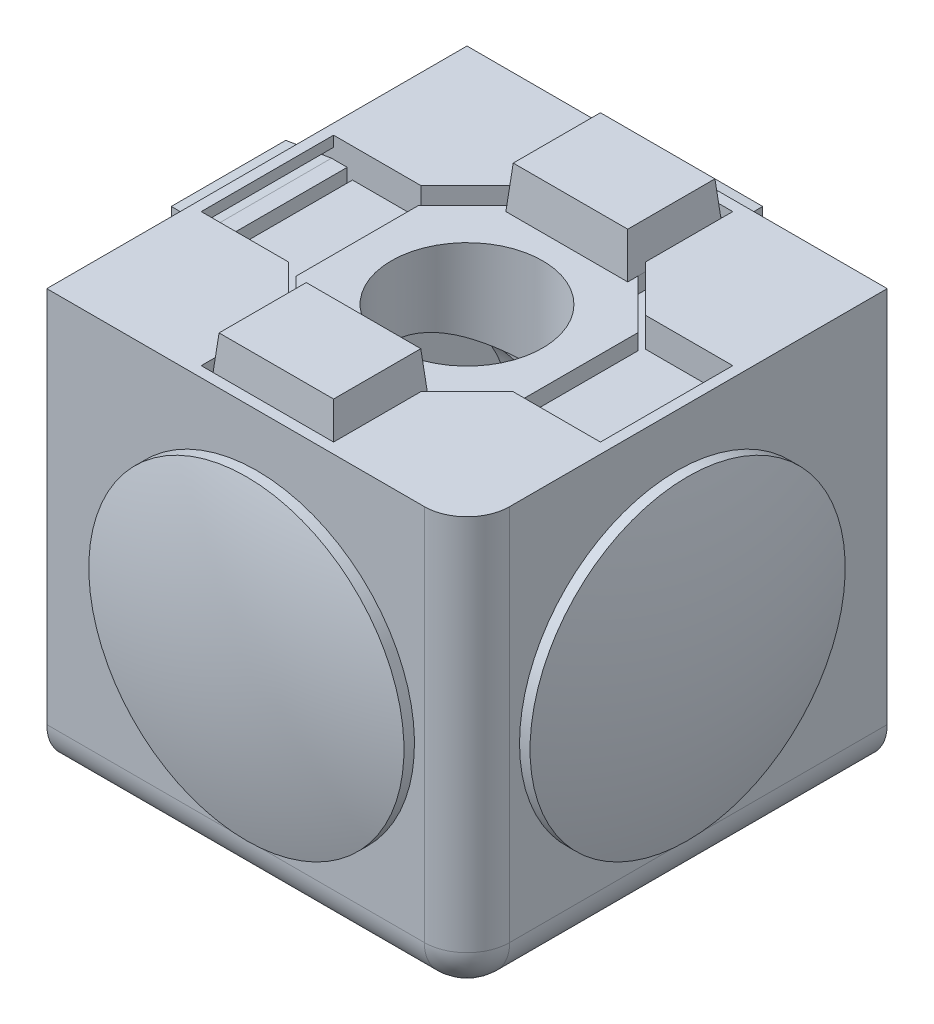
from build123d import *

# Parameters (mm, degrees)
SKETCH1_W                   = 20
SKETCH1_H                   = 20
EXTRUDE1_DEPTH              = 10
SKETCH2_R                   = 6
CUT_EXTRUDE1_DEPTH          = 25.494897428
EXTRUDE2_START              = -6
SKETCH4_R                   = 6
SKETCH4_R_2                 = 3.6
EXTRUDE2_DEPTH              = 6
CUT_EXTRUDE7_DEPTH          = 1.4
SKETCH15_R                  = 3.6
EXTRUDE4_DEPTH              = 0.75
SKETCH16_W                  = 5.8
SKETCH16_H                  = 4.5
EXTRUDE5_DEPTH              = 2
EXTRUDE5_DRAFT              = 5
EXTRUDE5_PROFILE_2_DEPTH    = 2
EXTRUDE5_PROFILE_2_DRAFT    = 5
CIRPATTERN1_COUNT           = 2
CIRPATTERN1_ANGLE           = 90
CIRPATTERN1_COPY_1_SKETCH_W = 5.8
CIRPATTERN1_COPY_1_SKETCH_H = 4.5
CIRPATTERN1_COPY_1_DEPTH    = 2
CIRPATTERN1_COPY_1_DRAFT    = 5
CIRPATTERN1_COPY_2_SKETCH_W = 5.8
CIRPATTERN1_COPY_2_SKETCH_H = 4.5
CIRPATTERN1_COPY_2_DEPTH    = 2
CIRPATTERN1_COPY_2_DRAFT    = 5
CIRPATTERN1_COPY_3_SKETCH_W = 5.8
CIRPATTERN1_COPY_3_SKETCH_H = 4.5
CIRPATTERN1_COPY_3_DEPTH    = 2
CIRPATTERN1_COPY_3_DRAFT    = 5
CIRPATTERN2_COUNT           = 2
CIRPATTERN2_ANGLE           = 90
CIRPATTERN2_COPY_1_SKETCH_W = 5.8
CIRPATTERN2_COPY_1_SKETCH_H = 4.5
CIRPATTERN2_COPY_1_DEPTH    = 2
CIRPATTERN2_COPY_1_DRAFT    = 5
CIRPATTERN2_COPY_2_SKETCH_W = 5.8
CIRPATTERN2_COPY_2_SKETCH_H = 4.5
CIRPATTERN2_COPY_2_DEPTH    = 2
CIRPATTERN2_COPY_2_DRAFT    = 5
CIRPATTERN2_COPY_3_SKETCH_W = 5.8
CIRPATTERN2_COPY_3_SKETCH_H = 4.5
CIRPATTERN2_COPY_3_DEPTH    = 2
CIRPATTERN2_COPY_3_DRAFT    = 5
FILLET2_R                   = 2.032


with BuildPart() as part:
    # Sketch1 → Extrude1 (new, symmetric)
    with BuildSketch(Plane.XY):
        Rectangle(SKETCH1_W, SKETCH1_H)
    extrude(amount=EXTRUDE1_DEPTH, both=True)

    # Sketch2 → Cut-Extrude1 (cut, through all)
    with BuildSketch(Plane.XY.offset(10)):
        Circle(SKETCH2_R)
    cut_extrude1 = extrude(amount=-CUT_EXTRUDE1_DEPTH, mode=Mode.SUBTRACT)

    # Cut-Extrude2 cone 1 section (through the dimple's axis) → Cut-Extrude2 (revolve, cut)
    with BuildSketch(Plane(origin=(0, 0, 10), x_dir=(0, -1, 0), z_dir=(1, 0, 0))):
        Polygon((0, 0), (7.05, 0), (0, 7.05), align=None)
    cut_extrude2 = revolve(axis=Axis((0, 0, 10), (0, 0, -1)), mode=Mode.SUBTRACT)

    # Sketch4 → Extrude2 (add)
    with BuildSketch(Plane(origin=(0, 0, -10), x_dir=(-1, 0, 0), z_dir=(0, 0, -1)).offset(EXTRUDE2_START)):
        with Locations(Location((0, 0, 0), (0, 0, 180))):
            Circle(SKETCH4_R)
        Circle(SKETCH4_R_2, mode=Mode.SUBTRACT)
    extrude2 = extrude(amount=EXTRUDE2_DEPTH)

    # Sketch14 → Cut-Extrude7 (cut)
    with BuildSketch(Plane(origin=(0, 0, -10), x_dir=(-1, 0, 0), z_dir=(0, 0, -1))):
        Polygon((-3.15, 5.335281374), (-5.335281374, 3.15), (-9.5, 3.15), (-9.5, -3.15), (-5.335281374, -3.15), (-3.15, -5.335281374), (-3.15, -9.5), (3.15, -9.5), (3.15, -5.335281374), (5.335281374, -3.15), (9.5, -3.15), (9.5, 3.15), (5.335281374, 3.15), (3.15, 5.335281374), (3.15, 9.5), (-3.15, 9.5), align=None)
    cut_extrude7 = extrude(amount=-CUT_EXTRUDE7_DEPTH, mode=Mode.SUBTRACT)

    # Sketch15 → Extrude4 (add)
    with BuildSketch(Plane(origin=(0, 0, -8.6), x_dir=(-1, 0, 0), z_dir=(0, 0, -1))):
        Polygon((-5.231727984, 2.9), (-5.231727984, -2.9), (-2.9, -5.231727984), (-2.9, -9.25), (2.9, -9.25), (2.9, -5.231727984), (5.231727984, -2.9), (5.231727984, 2.9), (2.9, 5.231727984), (2.9, 9.25), (-2.9, 9.25), (-2.9, 5.231727984), align=None)
        Circle(SKETCH15_R, mode=Mode.SUBTRACT)
    extrude4 = extrude(amount=EXTRUDE4_DEPTH)


with BuildPart() as extrude5_tool:
    # Sketch16 → Extrude5 (with draft: the straight prism first)
    with BuildSketch(Plane(origin=(0, 0, -9.35), x_dir=(-1, 0, 0), z_dir=(0, 0, -1))):
        with Locations((0, 7)):
            Rectangle(SKETCH16_W, SKETCH16_H)
    extrude(amount=EXTRUDE5_DEPTH)
    # Extrude5: the draft: its side faces are tilted about the plane it starts from
    extrude5_sides = [extrude5_tool.faces().sort_by_distance(p)[0] for p in [
        (2.9, 7, -10.35),
        (0, 4.75, -10.35),
        (-2.9, 7, -10.35),
        (0, 9.25, -10.35),
    ]]
    draft(extrude5_sides, Plane(origin=(0, 0, -9.35), x_dir=(-1, 0, 0), z_dir=(0, 0, -1)), EXTRUDE5_DRAFT)


with BuildPart() as part_1:
    add(part.part)

    # Extrude5: add extrude5_tool
    add(extrude5_tool.part)


with BuildPart() as extrude5_profile_2_tool:
    # Sketch16 → Extrude5 profile 2 (with draft: the straight prism first)
    with BuildSketch(Plane(origin=(0, 0, -9.35), x_dir=(-1, 0, 0), z_dir=(0, 0, -1))):
        with Locations((0, -7)):
            Rectangle(SKETCH16_W, SKETCH16_H)
    extrude(amount=EXTRUDE5_PROFILE_2_DEPTH)
    # Extrude5 profile 2: the draft: its side faces are tilted about the plane it starts from
    extrude5_profile_2_sides = [extrude5_profile_2_tool.faces().sort_by_distance(p)[0] for p in [
        (0, -9.25, -10.35),
        (-2.9, -7, -10.35),
        (0, -4.75, -10.35),
        (2.9, -7, -10.35),
    ]]
    draft(extrude5_profile_2_sides, Plane(origin=(0, 0, -9.35), x_dir=(-1, 0, 0), z_dir=(0, 0, -1)), EXTRUDE5_PROFILE_2_DRAFT)


with BuildPart() as part_2:
    add(part_1.part)

    # Extrude5 profile 2: add extrude5_profile_2_tool
    add(extrude5_profile_2_tool.part)

    # Sketch13 → Revolve1 (revolve)
    with BuildSketch(Plane(origin=(0, 0, 0), x_dir=(0, 0, -1), z_dir=(1, 0, 0)), mode=Mode.PRIVATE) as revolve1_sk:
        with BuildLine():
            Line((-10, -7.5), (-10, -6))
            Line((-10, -6), (-7, -6))
            Line((-7, -6), (-7, -5.5))
            Line((-7, -5.5), (-10, -5.5))
            Line((-10, -5.5), (-10, 0))
            Line((-10, 0), (-11.5, 0))
            ThreePointArc((-11.5, 0), (-11.248898657, -3.783186488), (-10.5, -7.5))
            Line((-10.5, -7.5), (-10, -7.5))
        make_face()
    revolve1 = revolve(revolve1_sk.sketch.rotate(Axis((0, 0, 0), (0, 0, 1)), 180), axis=Axis((0, 0, 0), (0, 0, 1)))

    # CirPattern1: Cut-Extrude1, Cut-Extrude2, Extrude2, Cut-Extrude7, Extrude4, Revolve1 ×2 about axis
    cirpattern1_axis = Axis((0, 0, 0), (1, 0, 0))
    add([cut_extrude1.rotate(cirpattern1_axis, i * CIRPATTERN1_ANGLE / (CIRPATTERN1_COUNT - 1)) for i in range(1, CIRPATTERN1_COUNT)], mode=Mode.SUBTRACT)
    add([cut_extrude2.rotate(cirpattern1_axis, i * CIRPATTERN1_ANGLE / (CIRPATTERN1_COUNT - 1)) for i in range(1, CIRPATTERN1_COUNT)], mode=Mode.SUBTRACT)
    add([extrude2.rotate(cirpattern1_axis, i * CIRPATTERN1_ANGLE / (CIRPATTERN1_COUNT - 1)) for i in range(1, CIRPATTERN1_COUNT)])
    add([cut_extrude7.rotate(cirpattern1_axis, i * CIRPATTERN1_ANGLE / (CIRPATTERN1_COUNT - 1)) for i in range(1, CIRPATTERN1_COUNT)], mode=Mode.SUBTRACT)
    add([extrude4.rotate(cirpattern1_axis, i * CIRPATTERN1_ANGLE / (CIRPATTERN1_COUNT - 1)) for i in range(1, CIRPATTERN1_COUNT)])
    add([revolve1.rotate(cirpattern1_axis, i * CIRPATTERN1_ANGLE / (CIRPATTERN1_COUNT - 1)) for i in range(1, CIRPATTERN1_COUNT)])


with BuildPart() as cirpattern1_copy_1_tool:
    # CirPattern1 copy 1 sketch → CirPattern1 copy 1 (with draft: the straight prism first)
    with BuildSketch(Plane(origin=(0, 9.35, 0), x_dir=(-1, 0, 0), z_dir=(0, 1, 0))):
        with Locations((0, 7)):
            Rectangle(CIRPATTERN1_COPY_1_SKETCH_W, CIRPATTERN1_COPY_1_SKETCH_H)
    extrude(amount=CIRPATTERN1_COPY_1_DEPTH)
    # CirPattern1 copy 1: the draft: its side faces are tilted about the plane it starts from
    cirpattern1_copy_1_sides = [cirpattern1_copy_1_tool.faces().sort_by_distance(p)[0] for p in [
        (2.9, 10.35, 7),
        (0, 10.35, 4.75),
        (-2.9, 10.35, 7),
        (0, 10.35, 9.25),
    ]]
    draft(cirpattern1_copy_1_sides, Plane(origin=(0, 9.35, 0), x_dir=(-1, 0, 0), z_dir=(0, 1, 0)), CIRPATTERN1_COPY_1_DRAFT)


with BuildPart() as part_3:
    add(part_2.part)

    # CirPattern1 copy 1: add cirpattern1_copy_1_tool
    add(cirpattern1_copy_1_tool.part)


with BuildPart() as cirpattern1_copy_2_tool:
    # CirPattern1 copy 2 sketch → CirPattern1 copy 2 (with draft: the straight prism first)
    with BuildSketch(Plane(origin=(0, 9.35, 0), x_dir=(-1, 0, 0), z_dir=(0, 1, 0))):
        with Locations((0, -7)):
            Rectangle(CIRPATTERN1_COPY_2_SKETCH_W, CIRPATTERN1_COPY_2_SKETCH_H)
    extrude(amount=CIRPATTERN1_COPY_2_DEPTH)
    # CirPattern1 copy 2: the draft: its side faces are tilted about the plane it starts from
    cirpattern1_copy_2_sides = [cirpattern1_copy_2_tool.faces().sort_by_distance(p)[0] for p in [
        (0, 10.35, -9.25),
        (-2.9, 10.35, -7),
        (0, 10.35, -4.75),
        (2.9, 10.35, -7),
    ]]
    draft(cirpattern1_copy_2_sides, Plane(origin=(0, 9.35, 0), x_dir=(-1, 0, 0), z_dir=(0, 1, 0)), CIRPATTERN1_COPY_2_DRAFT)


with BuildPart() as part_4:
    add(part_3.part)

    # CirPattern1 copy 2: add cirpattern1_copy_2_tool
    add(cirpattern1_copy_2_tool.part)


with BuildPart() as cirpattern1_copy_3_tool:
    # CirPattern1 copy 3 sketch → CirPattern1 copy 3 (with draft: the straight prism first)
    with BuildSketch(Plane(origin=(0, 9.35, 0), x_dir=(-1, 0, 0), z_dir=(0, 1, 0))):
        with Locations((0, -7)):
            Rectangle(CIRPATTERN1_COPY_3_SKETCH_W, CIRPATTERN1_COPY_3_SKETCH_H)
    extrude(amount=CIRPATTERN1_COPY_3_DEPTH)
    # CirPattern1 copy 3: the draft: its side faces are tilted about the plane it starts from
    cirpattern1_copy_3_sides = [cirpattern1_copy_3_tool.faces().sort_by_distance(p)[0] for p in [
        (0, 10.35, -9.25),
        (-2.9, 10.35, -7),
        (0, 10.35, -4.75),
        (2.9, 10.35, -7),
    ]]
    draft(cirpattern1_copy_3_sides, Plane(origin=(0, 9.35, 0), x_dir=(-1, 0, 0), z_dir=(0, 1, 0)), CIRPATTERN1_COPY_3_DRAFT)


with BuildPart() as part_5:
    add(part_4.part)

    # CirPattern1 copy 3: add cirpattern1_copy_3_tool
    add(cirpattern1_copy_3_tool.part)

    # CirPattern2: Cut-Extrude1, Cut-Extrude2, Extrude2, Cut-Extrude7, Extrude4, Revolve1 ×2 about axis
    cirpattern2_axis = Axis((0, 0, 0), (0, 1, 0))
    add([cut_extrude1.rotate(cirpattern2_axis, i * CIRPATTERN2_ANGLE / (CIRPATTERN2_COUNT - 1)) for i in range(1, CIRPATTERN2_COUNT)], mode=Mode.SUBTRACT)
    add([cut_extrude2.rotate(cirpattern2_axis, i * CIRPATTERN2_ANGLE / (CIRPATTERN2_COUNT - 1)) for i in range(1, CIRPATTERN2_COUNT)], mode=Mode.SUBTRACT)
    add([extrude2.rotate(cirpattern2_axis, i * CIRPATTERN2_ANGLE / (CIRPATTERN2_COUNT - 1)) for i in range(1, CIRPATTERN2_COUNT)])
    add([cut_extrude7.rotate(cirpattern2_axis, i * CIRPATTERN2_ANGLE / (CIRPATTERN2_COUNT - 1)) for i in range(1, CIRPATTERN2_COUNT)], mode=Mode.SUBTRACT)
    add([extrude4.rotate(cirpattern2_axis, i * CIRPATTERN2_ANGLE / (CIRPATTERN2_COUNT - 1)) for i in range(1, CIRPATTERN2_COUNT)])
    add([revolve1.rotate(cirpattern2_axis, i * CIRPATTERN2_ANGLE / (CIRPATTERN2_COUNT - 1)) for i in range(1, CIRPATTERN2_COUNT)])


with BuildPart() as cirpattern2_copy_1_tool:
    # CirPattern2 copy 1 sketch → CirPattern2 copy 1 (with draft: the straight prism first)
    with BuildSketch(Plane.ZY.offset(9.35)):
        with Locations((0, 7)):
            Rectangle(CIRPATTERN2_COPY_1_SKETCH_W, CIRPATTERN2_COPY_1_SKETCH_H)
    extrude(amount=CIRPATTERN2_COPY_1_DEPTH)
    # CirPattern2 copy 1: the draft: its side faces are tilted about the plane it starts from
    cirpattern2_copy_1_sides = [cirpattern2_copy_1_tool.faces().sort_by_distance(p)[0] for p in [
        (-10.35, 7, -2.9),
        (-10.35, 4.75, 0),
        (-10.35, 7, 2.9),
        (-10.35, 9.25, 0),
    ]]
    draft(cirpattern2_copy_1_sides, Plane.ZY.offset(9.35), CIRPATTERN2_COPY_1_DRAFT)


with BuildPart() as part_6:
    add(part_5.part)

    # CirPattern2 copy 1: add cirpattern2_copy_1_tool
    add(cirpattern2_copy_1_tool.part)


with BuildPart() as cirpattern2_copy_2_tool:
    # CirPattern2 copy 2 sketch → CirPattern2 copy 2 (with draft: the straight prism first)
    with BuildSketch(Plane.ZY.offset(9.35)):
        with Locations((0, -7)):
            Rectangle(CIRPATTERN2_COPY_2_SKETCH_W, CIRPATTERN2_COPY_2_SKETCH_H)
    extrude(amount=CIRPATTERN2_COPY_2_DEPTH)
    # CirPattern2 copy 2: the draft: its side faces are tilted about the plane it starts from
    cirpattern2_copy_2_sides = [cirpattern2_copy_2_tool.faces().sort_by_distance(p)[0] for p in [
        (-10.35, -9.25, 0),
        (-10.35, -7, 2.9),
        (-10.35, -4.75, 0),
        (-10.35, -7, -2.9),
    ]]
    draft(cirpattern2_copy_2_sides, Plane.ZY.offset(9.35), CIRPATTERN2_COPY_2_DRAFT)


with BuildPart() as part_7:
    add(part_6.part)

    # CirPattern2 copy 2: add cirpattern2_copy_2_tool
    add(cirpattern2_copy_2_tool.part)


with BuildPart() as cirpattern2_copy_3_tool:
    # CirPattern2 copy 3 sketch → CirPattern2 copy 3 (with draft: the straight prism first)
    with BuildSketch(Plane.ZY.offset(9.35)):
        with Locations((0, -7)):
            Rectangle(CIRPATTERN2_COPY_3_SKETCH_W, CIRPATTERN2_COPY_3_SKETCH_H)
    extrude(amount=CIRPATTERN2_COPY_3_DEPTH)
    # CirPattern2 copy 3: the draft: its side faces are tilted about the plane it starts from
    cirpattern2_copy_3_sides = [cirpattern2_copy_3_tool.faces().sort_by_distance(p)[0] for p in [
        (-10.35, -9.25, 0),
        (-10.35, -7, 2.9),
        (-10.35, -4.75, 0),
        (-10.35, -7, -2.9),
    ]]
    draft(cirpattern2_copy_3_sides, Plane.ZY.offset(9.35), CIRPATTERN2_COPY_3_DRAFT)


with BuildPart() as part_8:
    add(part_7.part)

    # CirPattern2 copy 3: add cirpattern2_copy_3_tool
    add(cirpattern2_copy_3_tool.part)

    # Fillet2
    fillet2_edges = [part_8.edges().sort_by_distance(p)[0] for p in [
        (10, 0, 10),
        (0, -10, 10),
        (10, -10, 0),
    ]]
    fillet(fillet2_edges, radius=FILLET2_R)


solid = part_8.part
